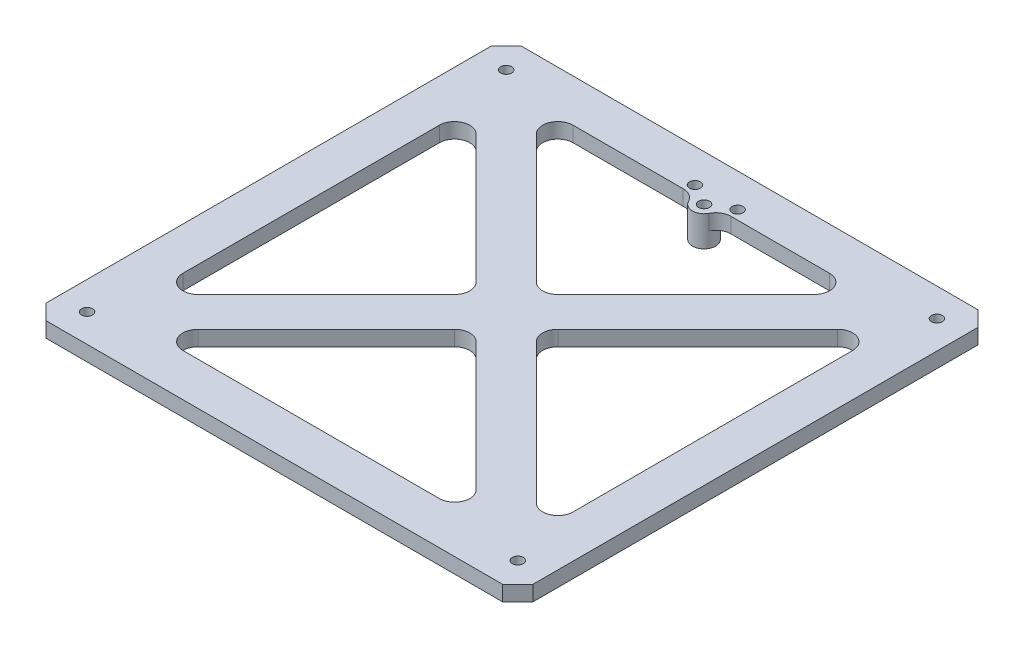
from build123d import *

# Parameters (mm, degrees)
BOSS_EXTRUDE1_DEPTH = 6.35
CUT_EXTRUDE1_DEPTH  = 7.35
SKETCH3_R           = 2.286
CUT_EXTRUDE2_DEPTH  = 7.35
BOSS_EXTRUDE2_DEPTH = 6.35
SKETCH5_R           = 4.826
BOSS_EXTRUDE3_DEPTH = 6.35
SKETCH6_R           = 2.286
CUT_EXTRUDE3_DEPTH  = 13.7


with BuildPart() as part:
    # Sketch1 → Boss-Extrude1 (new body)
    with BuildSketch(Plane(origin=(0, 0, 0), x_dir=(1, 0, 0), z_dir=(0, 1, 0))):
        Polygon((0, 192.024), (6.35, 198.374), (196.85, 198.374), (203.2, 192.024), (203.2, 6.35), (196.85, 0), (6.35, 0), (0, 6.35), align=None)
    extrude(amount=BOSS_EXTRUDE1_DEPTH)

    # Sketch2 → Cut-Extrude1 (cut, through all)
    with BuildSketch(Plane(origin=(0, 6.35, 0), x_dir=(1, 0, 0), z_dir=(0, 1, 0))):
        with BuildLine():
            Line((45.682614691, 180.594), (152.691385309, 180.594))
            ThreePointArc((152.691385309, 180.594), (158.558020341, 176.674039796), (157.18151337, 169.753871939))
            Line((157.18151337, 169.753871939), (103.677128061, 116.24948663))
            ThreePointArc((103.677128061, 116.24948663), (99.187, 114.389614691), (94.696871939, 116.24948663))
            Line((94.696871939, 116.24948663), (41.19248663, 169.753871939))
            ThreePointArc((41.19248663, 169.753871939), (39.815979659, 176.674039796), (45.682614691, 180.594))
        make_face()
        with BuildLine():
            Line((17.78, 152.691385309), (17.78, 45.682614691))
            ThreePointArc((17.78, 45.682614691), (21.699960204, 39.815979659), (28.620128061, 41.19248663))
            Line((28.620128061, 41.19248663), (82.12451337, 94.696871939))
            ThreePointArc((82.12451337, 94.696871939), (83.984385309, 99.187), (82.12451337, 103.677128061))
            Line((82.12451337, 103.677128061), (28.620128061, 157.18151337))
            ThreePointArc((28.620128061, 157.18151337), (21.699960204, 158.558020341), (17.78, 152.691385309))
        make_face()
        with BuildLine():
            Line((45.682614691, 17.78), (152.691385309, 17.78))
            ThreePointArc((152.691385309, 17.78), (158.558020341, 21.699960204), (157.18151337, 28.620128061))
            Line((157.18151337, 28.620128061), (103.677128061, 82.12451337))
            ThreePointArc((103.677128061, 82.12451337), (99.187, 83.984385309), (94.696871939, 82.12451337))
            Line((94.696871939, 82.12451337), (41.19248663, 28.620128061))
            ThreePointArc((41.19248663, 28.620128061), (39.815979659, 21.699960204), (45.682614691, 17.78))
        make_face()
        with BuildLine():
            Line((185.42, 157.517385309), (185.42, 40.856614691))
            ThreePointArc((185.42, 40.856614691), (181.500039796, 34.989979659), (174.579871939, 36.36648663))
            Line((174.579871939, 36.36648663), (116.24948663, 94.696871939))
            ThreePointArc((116.24948663, 94.696871939), (114.389614691, 99.187), (116.24948663, 103.677128061))
            Line((116.24948663, 103.677128061), (174.579871939, 162.00751337))
            ThreePointArc((174.579871939, 162.00751337), (181.500039796, 163.384020341), (185.42, 157.517385309))
        make_face()
    extrude(amount=-CUT_EXTRUDE1_DEPTH, mode=Mode.SUBTRACT)

    # Sketch3 → Cut-Extrude2 (cut, through all)
    with BuildSketch(Plane(origin=(0, 6.35, 0), x_dir=(1, 0, 0), z_dir=(0, 1, 0))):
        with Locations((11.73734, 11.73734)):
            Circle(SKETCH3_R)
        with Locations((191.46266, 11.73734)):
            Circle(SKETCH3_R)
        with Locations((191.46266, 186.63666)):
            Circle(SKETCH3_R)
        with Locations((11.73734, 186.63666)):
            Circle(SKETCH3_R)
    extrude(amount=-CUT_EXTRUDE2_DEPTH, mode=Mode.SUBTRACT)

    # Sketch4 → Boss-Extrude2 (add)
    with BuildSketch(Plane(origin=(0, 6.35, 0), x_dir=(1, 0, 0), z_dir=(0, 1, 0))):
        with BuildLine():
            Line((111.554726315, 180.594), (91.645273685, 180.594))
            ThreePointArc((91.645273685, 180.594), (94.961453031, 179.659298195), (97.301368182, 177.130363636))
            ThreePointArc((97.301368182, 177.130363636), (101.6, 174.498), (105.898631818, 177.130363636))
            ThreePointArc((105.898631818, 177.130363636), (108.238546969, 179.659298195), (111.554726315, 180.594))
        make_face()
    extrude(amount=-BOSS_EXTRUDE2_DEPTH)

    # Sketch5 → Boss-Extrude3 (add)
    with BuildSketch(Plane.XZ):
        with Locations((101.6, -179.324)):
            Circle(SKETCH5_R)
    extrude(amount=BOSS_EXTRUDE3_DEPTH)

    # Sketch6 → Cut-Extrude3 (cut, through all)
    with BuildSketch(Plane.XZ.offset(6.35)):
        with Locations((101.6, -179.324)):
            Circle(SKETCH6_R)
        with Locations((92.71, -184.404)):
            Circle(SKETCH6_R)
        with Locations((110.49, -184.404)):
            Circle(SKETCH6_R)
    extrude(amount=-CUT_EXTRUDE3_DEPTH, mode=Mode.SUBTRACT)


solid = part.part
